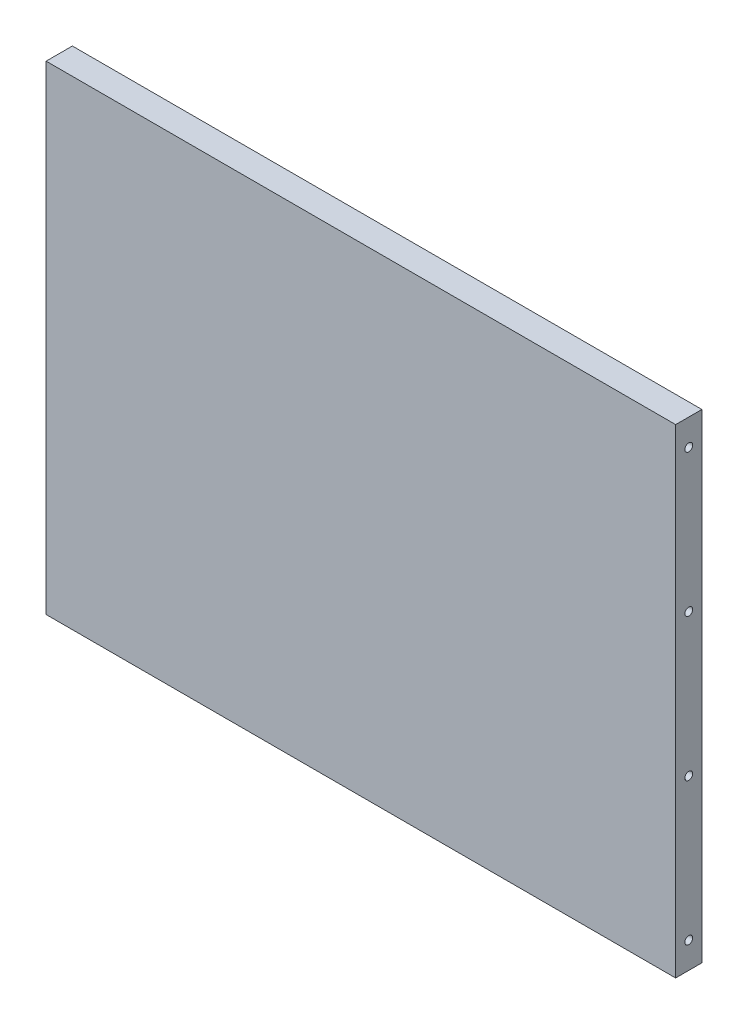
from build123d import *

# Parameters (mm, degrees)
SKETCH1_W                       = 304.799998662
SKETCH1_H                       = 232.05
BOSS_EXTRUDE1_DEPTH             = 12.7
F_10_24_TAPPED_HOLE1_AT_2_COUNT = 2
F_10_24_TAPPED_HOLE1_AT_2_PITCH = 68.883333333
F_10_24_TAPPED_HOLE1_AT_3_COUNT = 2
F_10_24_TAPPED_HOLE1_AT_3_PITCH = 137.766666667
F_10_24_TAPPED_HOLE1_AT_4_COUNT = 2
F_10_24_TAPPED_HOLE1_AT_4_PITCH = 206.65


with BuildPart() as part:
    # Sketch1 → Boss-Extrude1 (new body)
    with BuildSketch(Plane.XY):
        Rectangle(SKETCH1_W, SKETCH1_H)
    extrude(amount=-BOSS_EXTRUDE1_DEPTH)

    # Sketch3 → #10-24 Tapped Hole1 (revolve, cut)
    with BuildSketch(Plane(origin=(-152.399999331, 103.325, -6.35), x_dir=(0, 0, 1), z_dir=(0, 1, 0))):
        Polygon((0, 0), (0, 20.190824014), (1.89865, 19.05), (1.89865, 0), align=None)
    f_10_24_tapped_hole1 = revolve(axis=Axis((-158.749999331, 103.325, -6.35), (1, 0, 0)), mode=Mode.SUBTRACT)

    # #10-24 Tapped Hole1 at 2: #10-24 Tapped Hole1 ×2
    with Locations(*[(0, -i * F_10_24_TAPPED_HOLE1_AT_2_PITCH, 0) for i in range(1, F_10_24_TAPPED_HOLE1_AT_2_COUNT)]):
        add(f_10_24_tapped_hole1, mode=Mode.SUBTRACT)

    # #10-24 Tapped Hole1 at 3: #10-24 Tapped Hole1 ×2
    with Locations(*[(0, -i * F_10_24_TAPPED_HOLE1_AT_3_PITCH, 0) for i in range(1, F_10_24_TAPPED_HOLE1_AT_3_COUNT)]):
        add(f_10_24_tapped_hole1, mode=Mode.SUBTRACT)

    # #10-24 Tapped Hole1 at 4: #10-24 Tapped Hole1 ×2
    with Locations(*[(0, -i * F_10_24_TAPPED_HOLE1_AT_4_PITCH, 0) for i in range(1, F_10_24_TAPPED_HOLE1_AT_4_COUNT)]):
        add(f_10_24_tapped_hole1, mode=Mode.SUBTRACT)

    # Mirror1: #10-24 Tapped Hole1 across plane
    add(f_10_24_tapped_hole1.mirror(Plane(origin=(0, 0, 0), x_dir=(0, 0, 1), z_dir=(1, 0, 0))), mode=Mode.SUBTRACT)

    # Mirror1 copy 1 sketch → Mirror1 copy 1 (revolve, cut)
    with BuildSketch(Plane(origin=(152.399999331, 34.441666667, -6.35), x_dir=(0, 0, 1), z_dir=(0, 1, 0))):
        Polygon((0, 0), (0, -20.190824014), (1.89865, -19.05), (1.89865, 0), align=None)
    revolve(axis=Axis((158.749999331, 34.441666667, -6.35), (1, 0, 0)), mode=Mode.SUBTRACT)

    # Mirror1 copy 2 sketch → Mirror1 copy 2 (revolve, cut)
    with BuildSketch(Plane(origin=(152.399999331, -34.441666667, -6.35), x_dir=(0, 0, 1), z_dir=(0, 1, 0))):
        Polygon((0, 0), (0, -20.190824014), (1.89865, -19.05), (1.89865, 0), align=None)
    revolve(axis=Axis((158.749999331, -34.441666667, -6.35), (1, 0, 0)), mode=Mode.SUBTRACT)

    # Mirror1 copy 3 sketch → Mirror1 copy 3 (revolve, cut)
    with BuildSketch(Plane(origin=(152.399999331, -103.325, -6.35), x_dir=(0, 0, 1), z_dir=(0, 1, 0))):
        Polygon((0, 0), (0, -20.190824014), (1.89865, -19.05), (1.89865, 0), align=None)
    revolve(axis=Axis((158.749999331, -103.325, -6.35), (1, 0, 0)), mode=Mode.SUBTRACT)


solid = part.part
